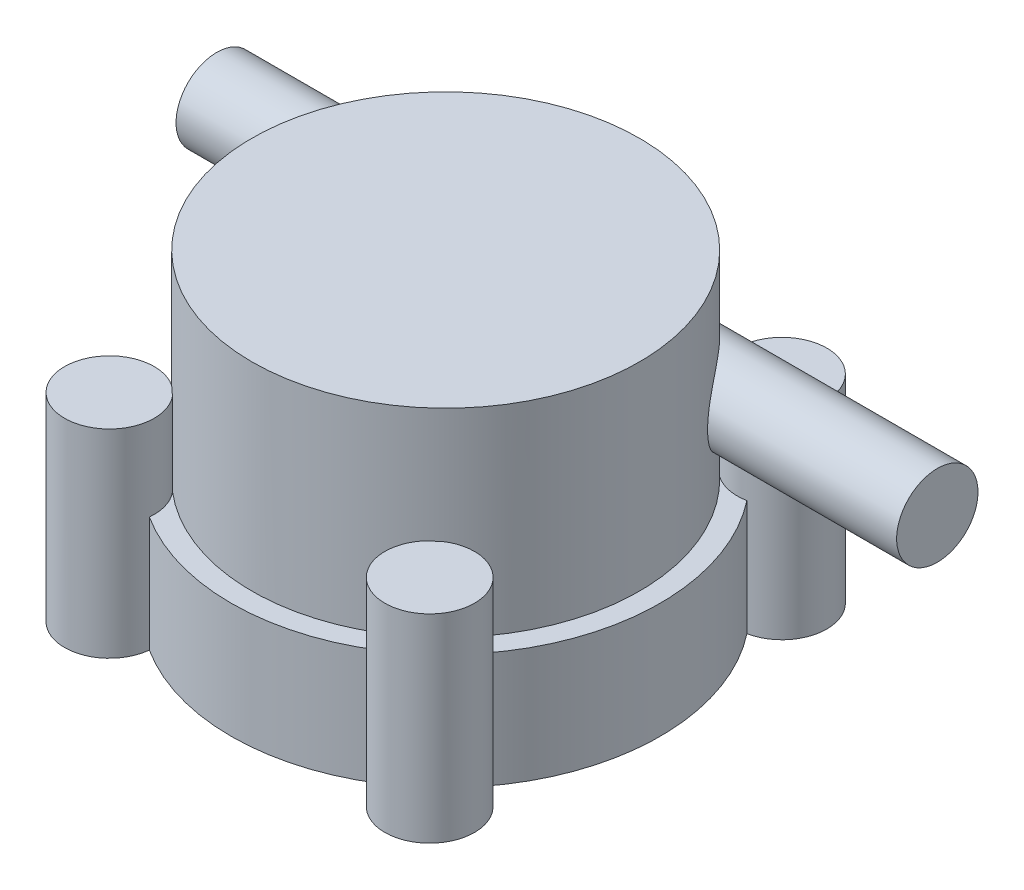
from build123d import *

# Parameters (mm, degrees)
SKETCH1_R           = 16.75
BOSS_EXTRUDE1_DEPTH = 9
SKETCH2_R           = 15.125
BOSS_EXTRUDE2_DEPTH = 15.5
SKETCH3_R           = 3.5
BOSS_EXTRUDE3_DEPTH = 15.5
BOSS_EXTRUDE4_START = -15.5
SKETCH4_R           = 3.175
BOSS_EXTRUDE4_DEPTH = 28.5


with BuildPart() as part:
    # Sketch1 → Boss-Extrude1 (new body)
    with BuildSketch(Plane(origin=(0, 0, 0), x_dir=(1, 0, 0), z_dir=(0, 1, 0))):
        Circle(SKETCH1_R)
    extrude(amount=BOSS_EXTRUDE1_DEPTH)

    # Sketch2 → Boss-Extrude2 (add)
    with BuildSketch(Plane(origin=(0, 9, 0), x_dir=(1, 0, 0), z_dir=(0, 1, 0))):
        Circle(SKETCH2_R)
    extrude(amount=BOSS_EXTRUDE2_DEPTH)

    # Sketch3 → Boss-Extrude3 (add)
    with BuildSketch(Plane.XZ):
        with Locations((-12.5, 13.75)):
            Circle(SKETCH3_R)
        with Locations((12.5, 13.75)):
            Circle(SKETCH3_R)
        with Locations((12.5, -13.75)):
            Circle(SKETCH3_R)
        with Locations((-12.5, -13.75)):
            Circle(SKETCH3_R)
    extrude(amount=-BOSS_EXTRUDE3_DEPTH)

    # Sketch4 → Boss-Extrude4 (add)
    with BuildSketch(Plane(origin=(15.125, 0, 0), x_dir=(0, 0, -1), z_dir=(1, 0, 0)).offset(BOSS_EXTRUDE4_START)):
        with Locations((10.25, 15.5)):
            Circle(SKETCH4_R)
    boss_extrude4 = extrude(amount=BOSS_EXTRUDE4_DEPTH)

    # Mirror1: Boss-Extrude4 across plane
    add(boss_extrude4.mirror(Plane(origin=(0, 0, 0), x_dir=(0, 0, 1), z_dir=(1, 0, 0))))


solid = part.part
